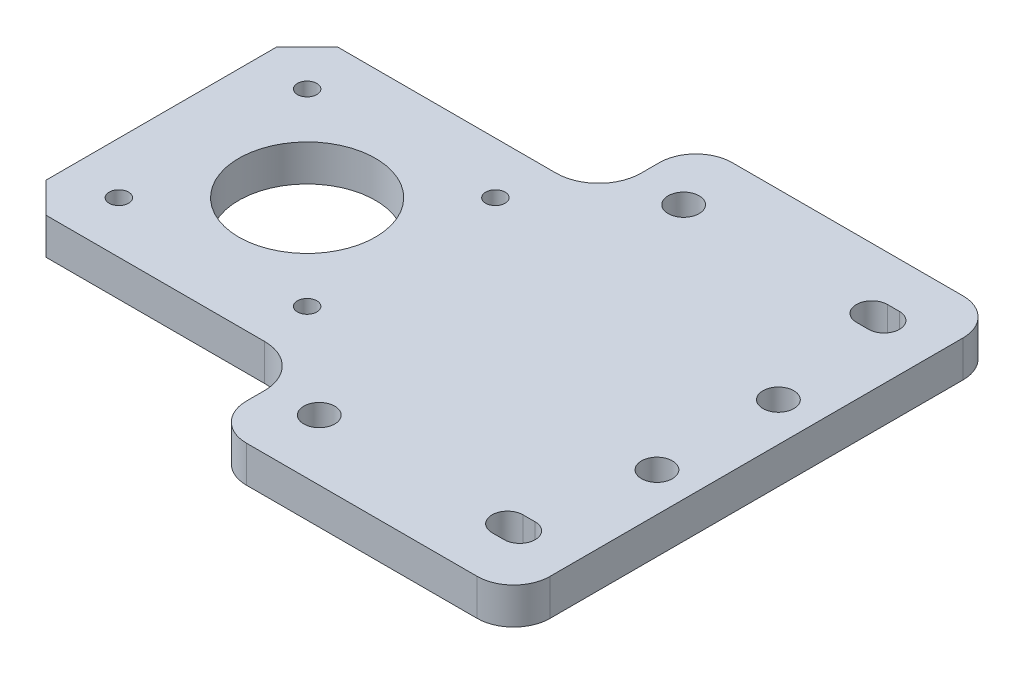
from build123d import *

# Parameters (mm, degrees)
SKETCH_1_R          = 11.25
SKETCH_1_R_2        = 1.6
SKETCH_1_R_3        = 2.550000002
EXTRUDE_1_DEPTH     = 6
SKETCH_2_R          = 2.55
CUT_EXTRUDE_1_DEPTH = 7


with BuildPart() as part:
    # Эскиз1 → Бобышка-Вытянуть1 (new body)
    with BuildSketch(Plane(origin=(0, 0, 0), x_dir=(1, 0, 0), z_dir=(0, 1, 0))):
        with BuildLine():
            Line((-32, -24), (-68, -24))
            Line((-68, -24), (-73, -19))
            Line((-73, -19), (-73, 19))
            Line((-73, 19), (-68, 24))
            Line((-68, 24), (-32, 24))
            ThreePointArc((-32, 24), (-27.050252532, 26.050252532), (-25, 31))
            Line((-25, 31), (-25, 34))
            ThreePointArc((-25, 34), (-23.242640687, 38.242640687), (-19, 40))
            Line((-19, 40), (19, 40))
            ThreePointArc((19, 40), (23.242640687, 38.242640687), (25, 34))
            Line((25, 34), (25, -34))
            ThreePointArc((25, -34), (23.242640687, -38.242640687), (19, -40))
            Line((19, -40), (-19, -40))
            ThreePointArc((-19, -40), (-23.242640687, -38.242640687), (-25, -34))
            Line((-25, -34), (-25, -31))
            ThreePointArc((-25, -31), (-27.050252532, -26.050252532), (-32, -24))
        make_face()
        with Locations((-49, 0)):
            Circle(SKETCH_1_R, mode=Mode.SUBTRACT)
        with Locations((-64.5, 15.5)):
            Circle(SKETCH_1_R_2, mode=Mode.SUBTRACT)
        with Locations((-64.5, -15.5)):
            Circle(SKETCH_1_R_2, mode=Mode.SUBTRACT)
        with Locations((-33.5, 15.5)):
            Circle(SKETCH_1_R_2, mode=Mode.SUBTRACT)
        with Locations((-33.5, -15.5)):
            Circle(SKETCH_1_R_2, mode=Mode.SUBTRACT)
        with Locations((18.604999997, -10)):
            Circle(SKETCH_1_R_3, mode=Mode.SUBTRACT)
        with Locations((18.604999997, 10)):
            Circle(SKETCH_1_R_3, mode=Mode.SUBTRACT)
    extrude(amount=EXTRUDE_1_DEPTH)

    # Эскиз2 → Вырез-Вытянуть1 (cut, through all)
    with BuildSketch(Plane.XZ):
        with Locations((-17, -30)):
            Circle(SKETCH_2_R)
        with Locations((-17, 30)):
            Circle(SKETCH_2_R)
        with BuildLine():
            Line((16, -32.55), (14, -32.55))
            ThreePointArc((14, -32.55), (11.45, -30), (14, -27.45))
            Line((14, -27.45), (16, -27.45))
            ThreePointArc((16, -27.45), (18.55, -30), (16, -32.55))
        make_face()
        with BuildLine():
            Line((16, 32.55), (14, 32.55))
            ThreePointArc((14, 32.55), (11.45, 30), (14, 27.45))
            Line((14, 27.45), (16, 27.45))
            ThreePointArc((16, 27.45), (18.55, 30), (16, 32.55))
        make_face()
    extrude(amount=-CUT_EXTRUDE_1_DEPTH, mode=Mode.SUBTRACT)


solid = part.part
